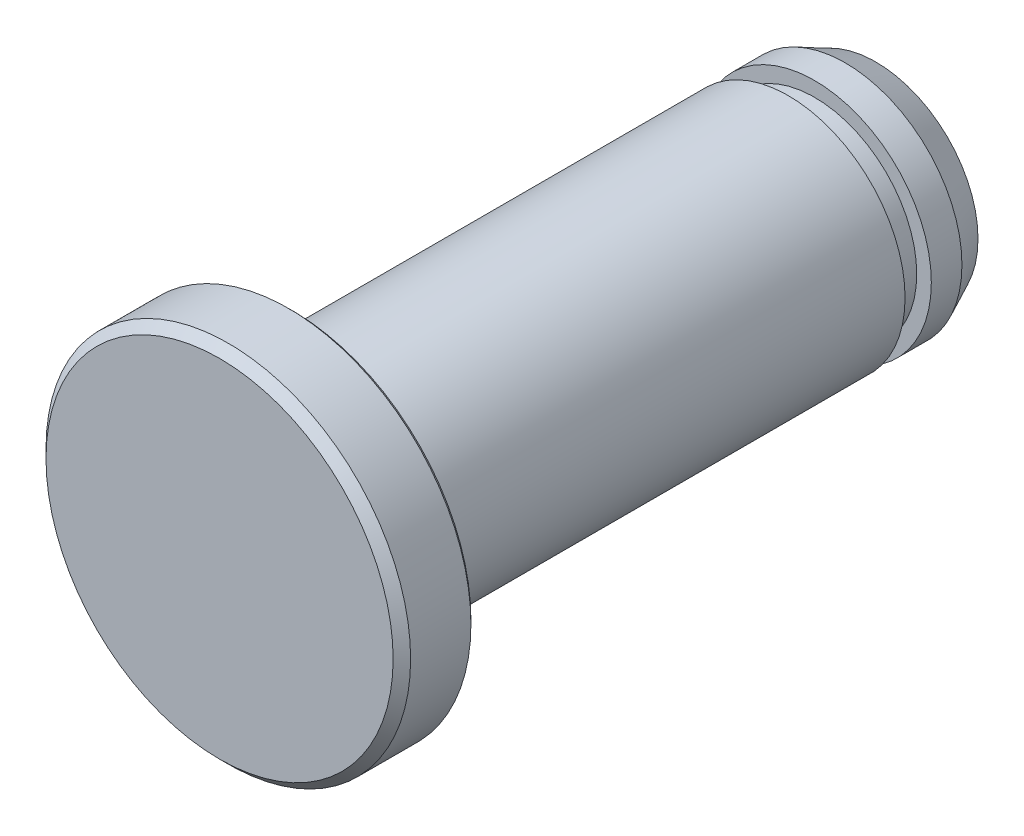
from build123d import *


with BuildPart() as part:
    # 草图3 → 旋转1 (revolve)
    with BuildSketch(Plane(origin=(0, 0, 0), x_dir=(0, 0, -1), z_dir=(1, 0, 0)), mode=Mode.PRIVATE) as revolve_1_sk:
        with BuildLine():
            Line((12.5, 0), (15.5, 0))
            Line((15.5, 0), (15.5, 3.5))
            Line((15.5, 3.5), (14.45, 4))
            Line((14.45, 4), (13.4, 4))
            Line((13.4, 4), (13.4, 3.5))
            Line((13.4, 3.5), (12.5, 3.5))
            Line((12.5, 3.5), (12.5, 4))
            Line((12.5, 4), (0, 4))
            Line((0, 4), (-4.333333333, 4))
            ThreePointArc((-4.333333333, 4), (-4.451184464, 4.048815536), (-4.5, 4.166666667))
            Line((-4.5, 4.166666667), (-4.5, 6.116666667))
            Line((-4.5, 6.116666667), (-4.633333333, 6.25))
            Line((-4.633333333, 6.25), (-6.7, 6.25))
            Line((-6.7, 6.25), (-7, 5.95))
            Line((-7, 5.95), (-7, 0))
            Line((-7, 0), (12.5, 0))
        make_face()
    revolve(revolve_1_sk.sketch.rotate(Axis((0, 0, 7), (0, 0, -1)), 90), axis=Axis((0, 0, 7), (0, 0, -1)))


solid = part.part
